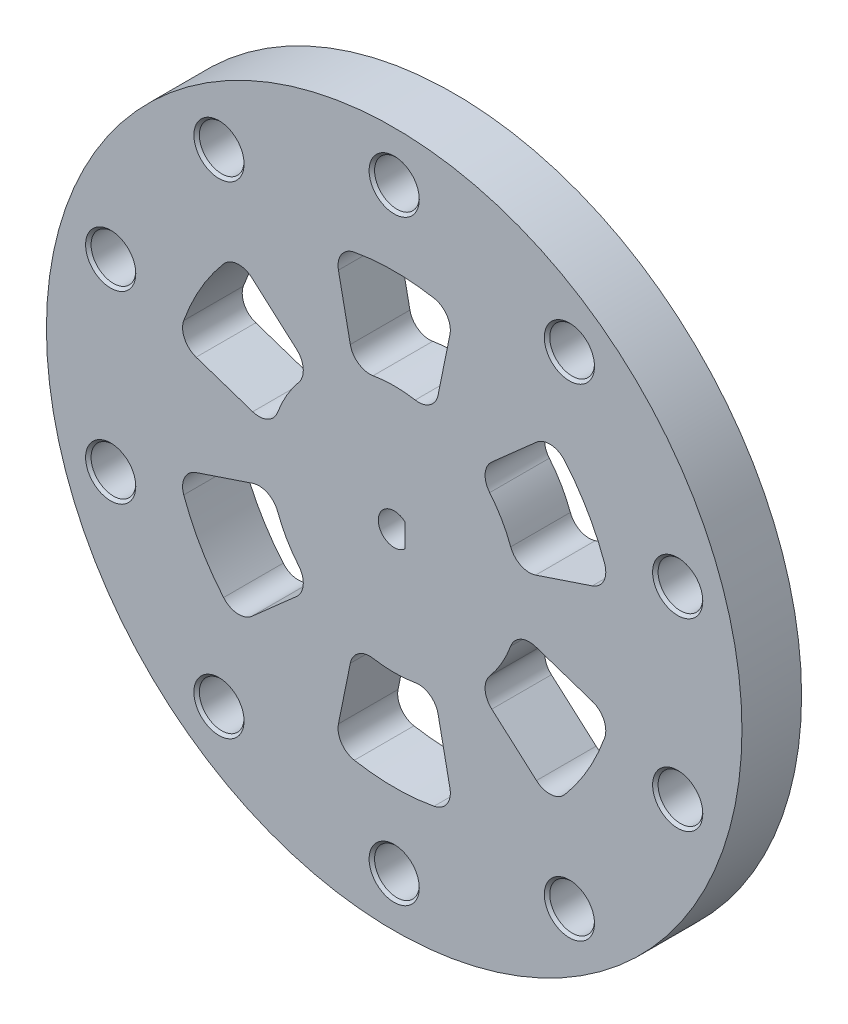
from build123d import *

# Parameters (mm, degrees)
SKETCH1_R               = 35
SKETCH1_R_2             = 12.5
BOSS_EXTRUDE2_DEPTH     = 3
FILLET1_R               = 2
CUT_EXTRUDE1_DEPTH      = 50.859803449
CUT_EXTRUDE1_DEPTH_BACK = 50.859803449
CIRPATTERN4_COUNT       = 10


with BuildPart() as part:
    # Sketch1 → Boss-Extrude2 (new, symmetric)
    with BuildSketch(Plane.XY):
        Circle(SKETCH1_R)
        with BuildLine():
            ThreePointArc((-8.256095748, 9.385461256), (-6.25, 10.825317547), (-4, 11.842719282))
            Line((-4, 11.842719282), (-6, 21.685248442))
            ThreePointArc((-6, 21.685248442), (0, 22.5), (6, 21.685248442))
            Line((6, 21.685248442), (4, 11.842719282))
            ThreePointArc((4, 11.842719282), (6.25, 10.825317547), (8.256095748, 9.385461256))
            Line((8.256095748, 9.385461256), (15.779976038, 16.038776644))
            ThreePointArc((15.779976038, 16.038776644), (19.485571585, 11.25), (21.779976038, 5.646471798))
            Line((21.779976038, 5.646471798), (12.256095748, 2.457258026))
            ThreePointArc((12.256095748, 2.457258026), (12.438874484, 1.234666584), (12.5, 0))
            ThreePointArc((12.5, 0), (12.438874484, -1.234666584), (12.256095748, -2.457258026))
            Line((12.256095748, -2.457258026), (21.779976038, -5.646471798))
            ThreePointArc((21.779976038, -5.646471798), (19.485571585, -11.25), (15.779976038, -16.038776644))
            Line((15.779976038, -16.038776644), (8.256095748, -9.385461256))
            ThreePointArc((8.256095748, -9.385461256), (6.25, -10.825317547), (4, -11.842719282))
            Line((4, -11.842719282), (6, -21.685248442))
            ThreePointArc((6, -21.685248442), (0, -22.5), (-6, -21.685248442))
            Line((-6, -21.685248442), (-4, -11.842719282))
            ThreePointArc((-4, -11.842719282), (-6.25, -10.825317547), (-8.256095748, -9.385461256))
            Line((-8.256095748, -9.385461256), (-15.779976038, -16.038776644))
            ThreePointArc((-15.779976038, -16.038776644), (-19.485571585, -11.25), (-21.779976038, -5.646471798))
            Line((-21.779976038, -5.646471798), (-12.256095748, -2.457258026))
            ThreePointArc((-12.256095748, -2.457258026), (-12.5, 0), (-12.256095748, 2.457258026))
            Line((-12.256095748, 2.457258026), (-21.779976038, 5.646471798))
            ThreePointArc((-21.779976038, 5.646471798), (-19.485571585, 11.25), (-15.779976038, 16.038776644))
            Line((-15.779976038, 16.038776644), (-8.256095748, 9.385461256))
        make_face(mode=Mode.SUBTRACT)
        Circle(SKETCH1_R_2)
    extrude(amount=BOSS_EXTRUDE2_DEPTH, both=True)

    # Fillet1
    fillet1_edges = [part.edges().sort_by_distance(p)[0] for p in [
        (8.256095748, -9.385461256, 0),
        (15.779976038, -16.038776644, 0),
        (21.779976038, -5.646471798, 0),
        (12.256095748, -2.457258026, 0),
        (-6, -21.685248442, 0),
        (6, -21.685248442, 0),
        (4, -11.842719282, 0),
        (-4, -11.842719282, 0),
        (-21.779976038, -5.646471798, 0),
        (-15.779976038, -16.038776644, 0),
        (-8.256095748, -9.385461256, 0),
        (-12.256095748, -2.457258026, 0),
        (-15.779976038, 16.038776644, 0),
        (-21.779976038, 5.646471798, 0),
        (-12.256095748, 2.457258026, 0),
        (-8.256095748, 9.385461256, 0),
        (6, 21.685248442, 0),
        (-6, 21.685248442, 0),
        (-4, 11.842719282, 0),
        (4, 11.842719282, 0),
        (21.779976038, 5.646471798, 0),
        (15.779976038, 16.038776644, 0),
        (8.256095748, 9.385461256, 0),
        (12.256095748, 2.457258026, 0),
    ]]
    fillet(fillet1_edges, radius=FILLET1_R)

    # Sketch4 → Cut-Extrude1 (cut, two sides)
    with BuildSketch(Plane(origin=(0, 0, -3), x_dir=(-1, 0, 0), z_dir=(0, 0, -1))) as cut_extrude1_sk:
        with BuildLine():
            Line((-1.1, 1.161895004), (-1.1, -1.161895004))
            ThreePointArc((-1.1, -1.161895004), (1.6, 0), (-1.1, 1.161895004))
        make_face()
    extrude(amount=CUT_EXTRUDE1_DEPTH, mode=Mode.SUBTRACT)
    extrude(cut_extrude1_sk.sketch, amount=-CUT_EXTRUDE1_DEPTH_BACK, mode=Mode.SUBTRACT)

    # Sketch6 → Ø5.0mm Dowel Hole1 (revolve, cut)
    with BuildSketch(Plane(origin=(0, 30, 3), x_dir=(0, -1, 0), z_dir=(1, 0, 0))):
        Polygon((0, 0), (0, 21.351936393), (2.25, 20), (2.25, 0.275), (2.525, 0), align=None)
    f_5_0mm_dowel_hole1 = revolve(axis=Axis((0, 30, 9.35), (0, 0, -1)), mode=Mode.SUBTRACT)

    # CirPattern4: Ø5.0mm Dowel Hole1 ×10 about axis
    cirpattern4_axis = Axis((0, 0, 0), (0, 0, 1))
    for i in range(1, CIRPATTERN4_COUNT):
        add(f_5_0mm_dowel_hole1.rotate(cirpattern4_axis, i * 360 / CIRPATTERN4_COUNT), mode=Mode.SUBTRACT)


solid = part.part
